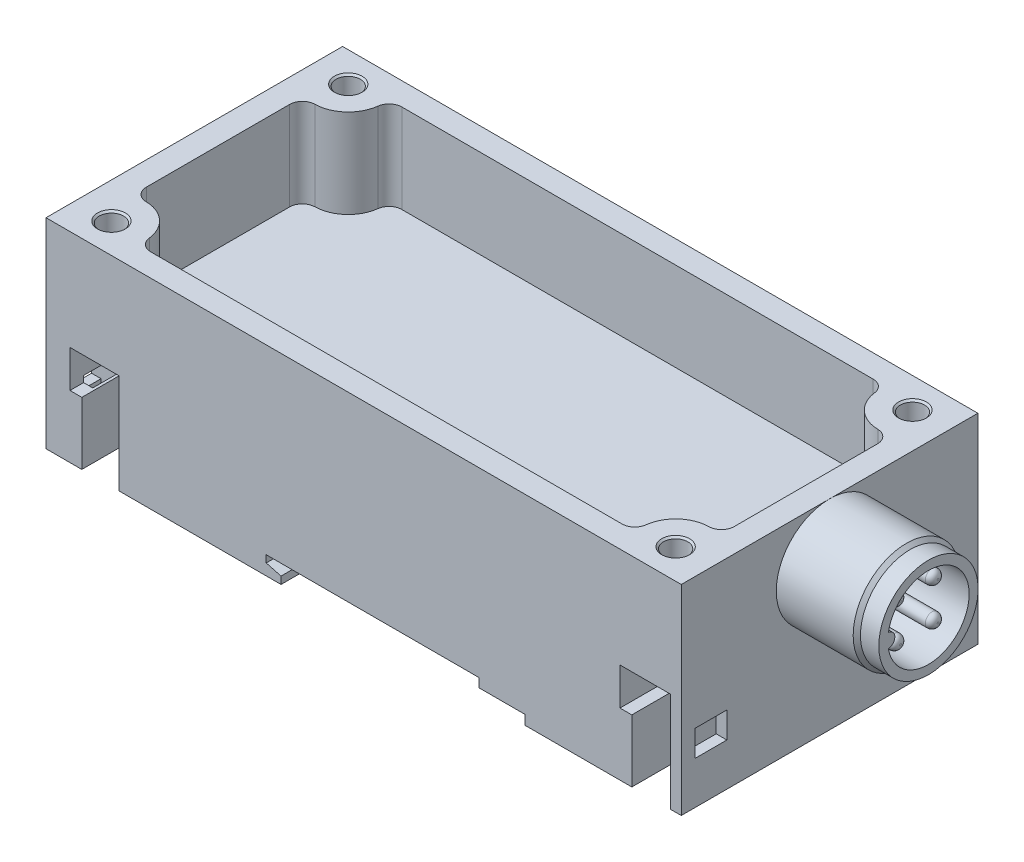
from build123d import *

# Parameters (mm, degrees)
BOSS_EXTRUDE1_DEPTH      = 25.05
BOSS_EXTRUDE1_DEPTH_BACK = 25.05
CUT_EXTRUDE1_DEPTH       = 15
SKETCH7_W                = 5.4
SKETCH7_H                = 4.4
CUT_EXTRUDE2_DEPTH       = 3
SKETCH8_W                = 5.4
SKETCH8_H                = 4.4
CUT_EXTRUDE3_DEPTH       = 3
SKETCH9_W                = 5.4
SKETCH9_H                = 4.4
CUT_EXTRUDE4_DEPTH       = 5
SKETCH10_W               = 5.4
SKETCH10_H               = 4.4
CUT_EXTRUDE5_DEPTH       = 5
BOSS_EXTRUDE2_DEPTH      = 16.7
SKETCH17_W               = 5.4
SKETCH17_H               = 5.4
CUT_EXTRUDE6_DEPTH       = 4
SKETCH18_W               = 5.4
SKETCH18_H               = 5.4
CUT_EXTRUDE7_DEPTH       = 4


with BuildPart() as part:
    # Sketch1 → Boss-Extrude1 (new, two sides: drawn at the far end of the back side and taken through both)
    with BuildSketch(Plane.XY.offset(-BOSS_EXTRUDE1_DEPTH_BACK)):
        Polygon((-53.65, 33.8), (-53.65, 0), (-47.6, 0), (-47.6, 10.55), (-49.6, 10.55), (-49.6, 16.85), (-41.3, 16.85), (-41.3, 0), (-13.95, 0), (-13.95, 1.230127019), (-16.45, 1.9), (-16.45, 3.1), (19.45, 3.1), (19.45, 1.6), (27.25, 1.6), (27.25, 0), (45.3, 0), (45.3, 10.55), (43.3, 10.55), (43.3, 16.85), (51.85, 16.85), (51.85, 0), (53.65, 0), (53.65, 33.8), align=None)
    extrude(amount=BOSS_EXTRUDE1_DEPTH + BOSS_EXTRUDE1_DEPTH_BACK)

    # Sketch2 → Cut-Revolve1 (revolve, cut)
    with BuildSketch(Plane.XY.offset(20)):
        with BuildLine():
            Line((47.65, 33.8), (50, 33.8))
            Line((50, 33.8), (49.7, 33.5))
            Line((49.7, 33.5), (49.7, 26.6))
            ThreePointArc((49.7, 26.6), (49.641421356, 26.458578644), (49.5, 26.4))
            Line((49.5, 26.4), (49.02, 26.4))
            Line((49.02, 26.4), (48.95, 18.4))
            Line((48.95, 18.4), (47.65, 18.4))
            Line((47.65, 18.4), (47.65, 33.8))
        make_face()
    revolve(axis=Axis((47.65, 18.4, 20), (0, 1, 0)), mode=Mode.SUBTRACT)

    # Sketch3 → Cut-Revolve2 (revolve, cut)
    with BuildSketch(Plane.XY.offset(-20)):
        with BuildLine():
            Line((47.65, 33.8), (50, 33.8))
            Line((50, 33.8), (49.7, 33.5))
            Line((49.7, 33.5), (49.7, 26.6))
            ThreePointArc((49.7, 26.6), (49.641421356, 26.458578644), (49.5, 26.4))
            Line((49.5, 26.4), (49.02, 26.4))
            Line((49.02, 26.4), (48.95, 18.4))
            Line((48.95, 18.4), (47.65, 18.4))
            Line((47.65, 18.4), (47.65, 33.8))
        make_face()
    revolve(axis=Axis((47.65, 18.4, -20), (0, 1, 0)), mode=Mode.SUBTRACT)

    # Sketch4 → Cut-Revolve3 (revolve, cut)
    with BuildSketch(Plane.XY.offset(-20)):
        with BuildLine():
            Line((-47.65, 33.8), (-45.3, 33.8))
            Line((-45.3, 33.8), (-45.6, 33.5))
            Line((-45.6, 33.5), (-45.6, 26.6))
            ThreePointArc((-45.6, 26.6), (-45.658578644, 26.458578644), (-45.8, 26.4))
            Line((-45.8, 26.4), (-46.28, 26.4))
            Line((-46.28, 26.4), (-46.35, 18.4))
            Line((-46.35, 18.4), (-47.65, 18.4))
            Line((-47.65, 18.4), (-47.65, 33.8))
        make_face()
    revolve(axis=Axis((-47.65, 18.4, -20), (0, 1, 0)), mode=Mode.SUBTRACT)

    # Sketch5 → Cut-Revolve4 (revolve, cut)
    with BuildSketch(Plane.XY.offset(20)):
        with BuildLine():
            Line((-47.65, 33.8), (-45.3, 33.8))
            Line((-45.3, 33.8), (-45.6, 33.5))
            Line((-45.6, 33.5), (-45.6, 26.6))
            ThreePointArc((-45.6, 26.6), (-45.658578644, 26.458578644), (-45.8, 26.4))
            Line((-45.8, 26.4), (-46.28, 26.4))
            Line((-46.28, 26.4), (-46.35, 18.4))
            Line((-46.35, 18.4), (-47.65, 18.4))
            Line((-47.65, 18.4), (-47.65, 33.8))
        make_face()
    revolve(axis=Axis((-47.65, 18.4, 20), (0, 1, 0)), mode=Mode.SUBTRACT)

    # Sketch6 → Cut-Extrude1 (cut)
    with BuildSketch(Plane(origin=(0, 33.8, 0), x_dir=(1, 0, 0), z_dir=(0, 1, 0))):
        with BuildLine():
            Line((-39.807328261, -21.2), (39.807328261, -21.2))
            ThreePointArc((39.807328261, -21.2), (41.233271764, -20.659094505), (41.941726266, -19.308544304))
            ThreePointArc((41.941726266, -19.308544304), (43.795745244, -15.733008053), (47.540822869, -14.251036584))
            ThreePointArc((47.540822869, -14.251036584), (49.034644775, -13.607201525), (49.65, -12.101424179))
            Line((49.65, -12.101424179), (49.65, 12.101424179))
            ThreePointArc((49.65, 12.101424179), (49.034644745, 13.607201555), (47.540822785, 14.251036586))
            ThreePointArc((47.540822785, 14.251036586), (43.795745267, 15.733008032), (41.941726284, 19.308544159))
            ThreePointArc((41.941726284, 19.308544159), (41.233271819, 20.659094457), (39.807328261, 21.2))
            Line((39.807328261, 21.2), (-39.807328261, 21.2))
            ThreePointArc((-39.807328261, 21.2), (-41.233271718, 20.659094546), (-41.941726251, 19.308544426))
            ThreePointArc((-41.941726251, 19.308544426), (-43.795745113, 15.733008171), (-47.540822639, 14.251036589))
            ThreePointArc((-47.540822639, 14.251036589), (-49.034644694, 13.607201607), (-49.65, 12.101424179))
            Line((-49.65, 12.101424179), (-49.65, -12.101424179))
            ThreePointArc((-49.65, -12.101424179), (-49.034644783, -13.607201517), (-47.540822892, -14.251036584))
            ThreePointArc((-47.540822892, -14.251036584), (-43.795745253, -15.733008045), (-41.941726266, -19.308544304))
            ThreePointArc((-41.941726266, -19.308544304), (-41.233271764, -20.659094505), (-39.807328261, -21.2))
        make_face()
    extrude(amount=-CUT_EXTRUDE1_DEPTH, mode=Mode.SUBTRACT)

    # Sketch7 → Cut-Extrude2 (cut)
    with BuildSketch(Plane(origin=(53.65, 0, 0), x_dir=(0, 0, -1), z_dir=(1, 0, 0))):
        with Locations((20.05, 9.4)):
            Rectangle(SKETCH7_W, SKETCH7_H)
    extrude(amount=-CUT_EXTRUDE2_DEPTH, mode=Mode.SUBTRACT)

    # Sketch8 → Cut-Extrude3 (cut)
    with BuildSketch(Plane(origin=(53.65, 0, 0), x_dir=(0, 0, -1), z_dir=(1, 0, 0))):
        with Locations((-20.05, 9.4)):
            Rectangle(SKETCH8_W, SKETCH8_H)
    extrude(amount=-CUT_EXTRUDE3_DEPTH, mode=Mode.SUBTRACT)

    # Sketch9 → Cut-Extrude4 (cut)
    with BuildSketch(Plane(origin=(-53.65, 0, 0), x_dir=(0, 0, -1), z_dir=(1, 0, 0))):
        with Locations((20.05, 9.4)):
            Rectangle(SKETCH9_W, SKETCH9_H)
    extrude(amount=CUT_EXTRUDE4_DEPTH, mode=Mode.SUBTRACT)

    # Sketch10 → Cut-Extrude5 (cut)
    with BuildSketch(Plane(origin=(-53.65, 0, 0), x_dir=(0, 0, -1), z_dir=(1, 0, 0))):
        with Locations((-20.05, 9.4)):
            Rectangle(SKETCH10_W, SKETCH10_H)
    extrude(amount=CUT_EXTRUDE5_DEPTH, mode=Mode.SUBTRACT)

    # Sketch11 → Revolve1 (revolve)
    with BuildSketch(Plane.XY):
        Polygon((53.65, 24.8), (53.65, 33.8), (66.6365, 33.8), (67.25, 33.1865), (70.35, 33.1865), (70.35, 31.675), (55.85, 31.675), (55.85, 24.8), align=None)
    revolve(axis=Axis((70.35, 24.8, 0), (-1, 0, 0)))

    # Sketch12 → Boss-Extrude2 (add)
    with BuildSketch(Plane(origin=(53.65, 0, 0), x_dir=(0, 0, -1), z_dir=(1, 0, 0))):
        with BuildLine():
            ThreePointArc((-6.770272727, 25.995421348), (-6.875, 24.8), (-6.770272727, 23.604578652))
            ThreePointArc((-6.770272727, 23.604578652), (-5.675, 24.8), (-6.770272727, 25.995421348))
        make_face()
    extrude(amount=BOSS_EXTRUDE2_DEPTH)

    # Sketch13 → Revolve2 (revolve)
    with BuildSketch(Plane.XY.offset(-3.18)):
        with BuildLine():
            Line((53.65, 27.98), (53.65, 29.14))
            Line((53.65, 29.14), (67.8, 29.14))
            ThreePointArc((67.8, 29.14), (68.507106781, 28.847106781), (68.8, 28.14))
            Line((68.8, 28.14), (68.8, 27.98))
            Line((68.8, 27.98), (53.65, 27.98))
        make_face()
    revolve(axis=Axis((68.8, 27.98, -3.18), (-1, 0, 0)))

    # Sketch14 → Revolve3 (revolve)
    with BuildSketch(Plane.XY.offset(3.18)):
        with BuildLine():
            Line((53.65, 27.98), (53.65, 29.14))
            Line((53.65, 29.14), (67.8, 29.14))
            ThreePointArc((67.8, 29.14), (68.507106781, 28.847106781), (68.8, 28.14))
            Line((68.8, 28.14), (68.8, 27.98))
            Line((68.8, 27.98), (53.65, 27.98))
        make_face()
    revolve(axis=Axis((68.8, 27.98, 3.18), (-1, 0, 0)))

    # Sketch15 → Revolve4 (revolve)
    with BuildSketch(Plane.XY.offset(-3.18)):
        with BuildLine():
            Line((53.65, 21.62), (53.65, 22.78))
            Line((53.65, 22.78), (67.8, 22.78))
            ThreePointArc((67.8, 22.78), (68.507106781, 22.487106781), (68.8, 21.78))
            Line((68.8, 21.78), (68.8, 21.62))
            Line((68.8, 21.62), (53.65, 21.62))
        make_face()
    revolve(axis=Axis((68.8, 21.62, -3.18), (-1, 0, 0)))

    # Sketch16 → Revolve5 (revolve)
    with BuildSketch(Plane.XY.offset(3.18)):
        with BuildLine():
            Line((53.65, 21.62), (53.65, 22.78))
            Line((53.65, 22.78), (67.8, 22.78))
            ThreePointArc((67.8, 22.78), (68.507106781, 22.487106781), (68.8, 21.78))
            Line((68.8, 21.78), (68.8, 21.62))
            Line((68.8, 21.62), (53.65, 21.62))
        make_face()
    revolve(axis=Axis((68.8, 21.62, 3.18), (-1, 0, 0)))

    # Sketch17 → Cut-Extrude6 (cut)
    with BuildSketch(Plane(origin=(-52.05, 0, 0), x_dir=(0, 0, -1), z_dir=(1, 0, 0))):
        with Locations((-20.05, 8.9)):
            Rectangle(SKETCH17_W, SKETCH17_H)
    extrude(amount=CUT_EXTRUDE6_DEPTH, mode=Mode.SUBTRACT)

    # Sketch18 → Cut-Extrude7 (cut)
    with BuildSketch(Plane(origin=(-52.05, 0, 0), x_dir=(0, 0, -1), z_dir=(1, 0, 0))):
        with Locations((20.05, 8.9)):
            Rectangle(SKETCH18_W, SKETCH18_H)
    extrude(amount=CUT_EXTRUDE7_DEPTH, mode=Mode.SUBTRACT)


solid = part.part
